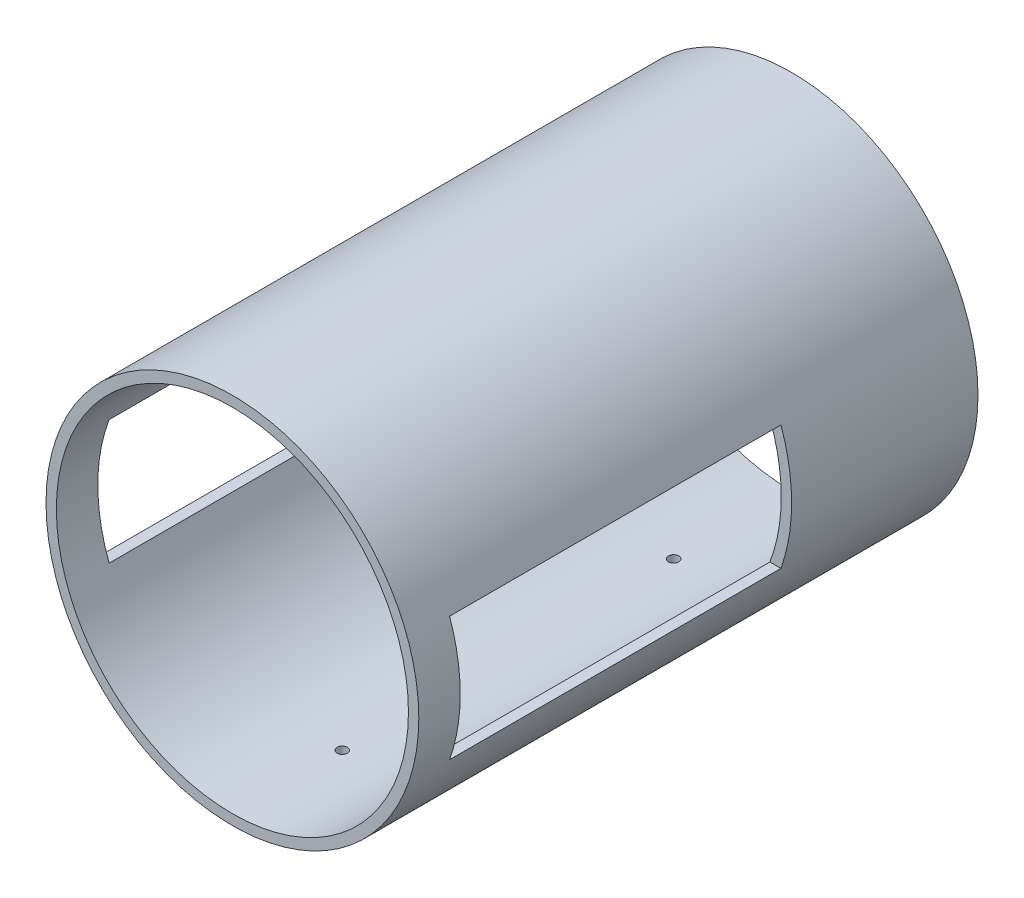
from build123d import *

# Parameters (mm, degrees)
SKETCH1_R               = 90
SKETCH1_R_2             = 85
BOSS_EXTRUDE1_DEPTH     = 270
SKETCH2_W               = 160
SKETCH2_H               = 60
CUT_EXTRUDE1_DEPTH      = 81
CUT_EXTRUDE1_DEPTH_BACK = 101
SKETCH3_R               = 2.5
CUT_EXTRUDE2_DEPTH      = 200


with BuildPart() as part:
    # Sketch1 → Boss-Extrude1 (new body)
    with BuildSketch(Plane.XY):
        Circle(SKETCH1_R)
        Circle(SKETCH1_R_2, mode=Mode.SUBTRACT)
    extrude(amount=BOSS_EXTRUDE1_DEPTH)

    # Sketch2 → Cut-Extrude1 (cut, two sides)
    with BuildSketch(Plane(origin=(10, 0, 0), x_dir=(0, 0, -1), z_dir=(1, 0, 0))) as cut_extrude1_sk:
        with Locations((-170, 0)):
            Rectangle(SKETCH2_W, SKETCH2_H)
    extrude(amount=CUT_EXTRUDE1_DEPTH, mode=Mode.SUBTRACT)
    extrude(cut_extrude1_sk.sketch, amount=-CUT_EXTRUDE1_DEPTH_BACK, mode=Mode.SUBTRACT)

    # Sketch3 → Cut-Extrude2 (cut)
    with BuildSketch(Plane(origin=(0, 10, 0), x_dir=(1, 0, 0), z_dir=(0, 1, 0))):
        with Locations((0, -216.93551415)):
            Circle(SKETCH3_R)
        with Locations((0, -56.93551415)):
            Circle(SKETCH3_R)
    extrude(amount=-CUT_EXTRUDE2_DEPTH, mode=Mode.SUBTRACT)


solid = part.part
